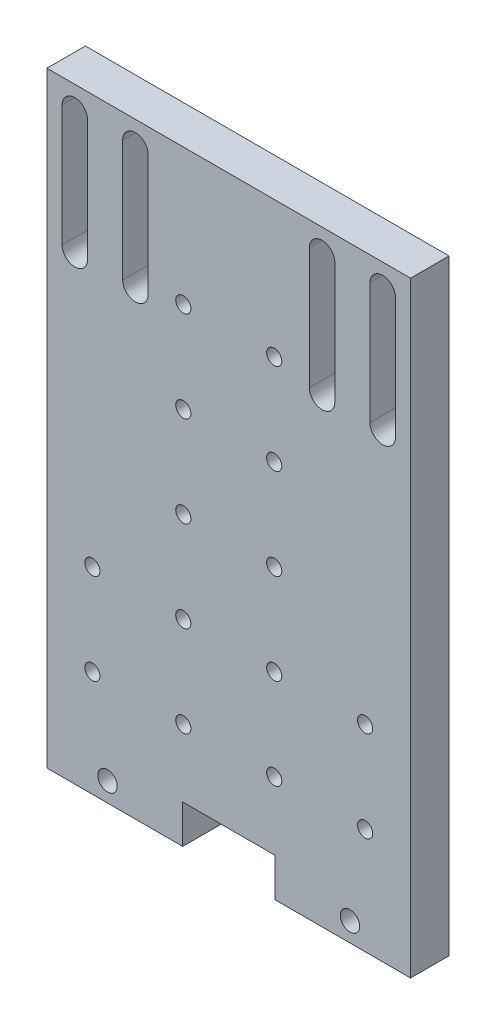
from build123d import *

# Parameters (mm, degrees)
BOSS_EXTRUDE1_DEPTH             = 6.35
F_2_5_2_5_DIAMETER_HOLE1_D      = 2.5
F_2_5_2_5_DIAMETER_HOLE1_DEPTH  = 6.35
F_3_2_3_2_DIAMETER_HOLE1_D      = 3.2
F_3_2_3_2_DIAMETER_HOLE1_DEPTH  = 6.35
F_2_5_2_5_DIAMETER_HOLE2_D      = 2.5
F_2_5_2_5_DIAMETER_HOLE2_DEPTH  = 6.35
F_2_5_2_5_DIAMETER_HOLE3_D      = 2.5
F_2_5_2_5_DIAMETER_HOLE3_DEPTH  = 6.35
F_2_5_2_5_DIAMETER_HOLE4_D      = 2.5
F_2_5_2_5_DIAMETER_HOLE4_DEPTH  = 6.35
F_2_5_2_5_DIAMETER_HOLE5_D      = 2.5
F_2_5_2_5_DIAMETER_HOLE5_DEPTH  = 6.35
F_2_5_2_5_DIAMETER_HOLE6_D      = 2.5
F_2_5_2_5_DIAMETER_HOLE6_DEPTH  = 6.35
F_2_5_2_5_DIAMETER_HOLE7_D      = 2.5
F_2_5_2_5_DIAMETER_HOLE7_DEPTH  = 6.35
F_2_5_2_5_DIAMETER_HOLE8_D      = 2.5
F_2_5_2_5_DIAMETER_HOLE8_DEPTH  = 6.35
F_2_5_2_5_DIAMETER_HOLE9_D      = 2.5
F_2_5_2_5_DIAMETER_HOLE9_DEPTH  = 6.35
F_2_5_2_5_DIAMETER_HOLE10_D     = 2.5
F_2_5_2_5_DIAMETER_HOLE10_DEPTH = 6.35
F_2_5_2_5_DIAMETER_HOLE11_D     = 2.5
F_2_5_2_5_DIAMETER_HOLE11_DEPTH = 6.35
F_2_5_2_5_DIAMETER_HOLE12_D     = 2.5
F_2_5_2_5_DIAMETER_HOLE12_DEPTH = 6.35
F_2_5_2_5_DIAMETER_HOLE13_D     = 2.5
F_2_5_2_5_DIAMETER_HOLE13_DEPTH = 6.35
F_2_5_2_5_DIAMETER_HOLE14_D     = 2.5
F_2_5_2_5_DIAMETER_HOLE14_DEPTH = 6.35
F_3_2_3_2_DIAMETER_HOLE2_D      = 3.2
F_3_2_3_2_DIAMETER_HOLE2_DEPTH  = 6.35
CUT_EXTRUDE1_DEPTH              = 7.35


with BuildPart() as part:
    # Sketch1 → Boss-Extrude1 (new body)
    with BuildSketch(Plane.XY.offset(118.288574318)):
        Polygon((19.634665341, 102.188959457), (19.634665341, 2.188959457), (42.034665341, 2.188959457), (42.034665341, 8.538959457), (57.234665341, 8.538959457), (57.234665341, 2.188959457), (79.634665341, 2.188959457), (79.634665341, 102.188959457), align=None)
    extrude(amount=-BOSS_EXTRUDE1_DEPTH)

    # Ø2.5 (2.5) Diameter Hole1
    with Locations(Plane(origin=(0, 0, 111.938574318), x_dir=(-1, 0, 0), z_dir=(0, 0, -1))):
        with Locations((-27.134665341, 19.688959457)):
            Hole(F_2_5_2_5_DIAMETER_HOLE1_D / 2, depth=F_2_5_2_5_DIAMETER_HOLE1_DEPTH)

    # Ø3.2 (3.2) Diameter Hole1
    with Locations(Plane.XY.offset(118.288574318)):
        with Locations((29.634665341, 5.363959457)):
            Hole(F_3_2_3_2_DIAMETER_HOLE1_D / 2, depth=F_3_2_3_2_DIAMETER_HOLE1_DEPTH)

    # Ø2.5 (2.5) Diameter Hole2
    with Locations(Plane(origin=(0, 0, 111.938574318), x_dir=(-1, 0, 0), z_dir=(0, 0, -1))):
        with Locations((-57.134665341, 19.688959457)):
            Hole(F_2_5_2_5_DIAMETER_HOLE2_D / 2, depth=F_2_5_2_5_DIAMETER_HOLE2_DEPTH)

    # Ø2.5 (2.5) Diameter Hole3
    with Locations(Plane(origin=(0, 0, 111.938574318), x_dir=(-1, 0, 0), z_dir=(0, 0, -1))):
        with Locations((-42.134665341, 34.688959457)):
            Hole(F_2_5_2_5_DIAMETER_HOLE3_D / 2, depth=F_2_5_2_5_DIAMETER_HOLE3_DEPTH)

    # Ø2.5 (2.5) Diameter Hole4
    with Locations(Plane(origin=(0, 0, 111.938574318), x_dir=(-1, 0, 0), z_dir=(0, 0, -1))):
        with Locations((-42.134665341, 64.688959457)):
            Hole(F_2_5_2_5_DIAMETER_HOLE4_D / 2, depth=F_2_5_2_5_DIAMETER_HOLE4_DEPTH)

    # Ø2.5 (2.5) Diameter Hole5
    with Locations(Plane(origin=(0, 0, 111.938574318), x_dir=(-1, 0, 0), z_dir=(0, 0, -1))):
        with Locations((-57.134665341, 64.688959457)):
            Hole(F_2_5_2_5_DIAMETER_HOLE5_D / 2, depth=F_2_5_2_5_DIAMETER_HOLE5_DEPTH)

    # Ø2.5 (2.5) Diameter Hole6
    with Locations(Plane(origin=(0, 0, 111.938574318), x_dir=(-1, 0, 0), z_dir=(0, 0, -1))):
        with Locations((-27.134665341, 34.688959457)):
            Hole(F_2_5_2_5_DIAMETER_HOLE6_D / 2, depth=F_2_5_2_5_DIAMETER_HOLE6_DEPTH)

    # Ø2.5 (2.5) Diameter Hole7
    with Locations(Plane(origin=(0, 0, 111.938574318), x_dir=(-1, 0, 0), z_dir=(0, 0, -1))):
        with Locations((-72.134665341, 19.688959457)):
            Hole(F_2_5_2_5_DIAMETER_HOLE7_D / 2, depth=F_2_5_2_5_DIAMETER_HOLE7_DEPTH)

    # Ø2.5 (2.5) Diameter Hole8
    with Locations(Plane(origin=(0, 0, 111.938574318), x_dir=(-1, 0, 0), z_dir=(0, 0, -1))):
        with Locations((-42.134665341, 19.688959457)):
            Hole(F_2_5_2_5_DIAMETER_HOLE8_D / 2, depth=F_2_5_2_5_DIAMETER_HOLE8_DEPTH)

    # Ø2.5 (2.5) Diameter Hole9
    with Locations(Plane(origin=(0, 0, 111.938574318), x_dir=(-1, 0, 0), z_dir=(0, 0, -1))):
        with Locations((-57.134665341, 34.688959457)):
            Hole(F_2_5_2_5_DIAMETER_HOLE9_D / 2, depth=F_2_5_2_5_DIAMETER_HOLE9_DEPTH)

    # Ø2.5 (2.5) Diameter Hole10
    with Locations(Plane(origin=(0, 0, 111.938574318), x_dir=(-1, 0, 0), z_dir=(0, 0, -1))):
        with Locations((-42.134665341, 49.688959457)):
            Hole(F_2_5_2_5_DIAMETER_HOLE10_D / 2, depth=F_2_5_2_5_DIAMETER_HOLE10_DEPTH)

    # Ø2.5 (2.5) Diameter Hole11
    with Locations(Plane(origin=(0, 0, 111.938574318), x_dir=(-1, 0, 0), z_dir=(0, 0, -1))):
        with Locations((-42.134665341, 79.688959457)):
            Hole(F_2_5_2_5_DIAMETER_HOLE11_D / 2, depth=F_2_5_2_5_DIAMETER_HOLE11_DEPTH)

    # Ø2.5 (2.5) Diameter Hole12
    with Locations(Plane(origin=(0, 0, 111.938574318), x_dir=(-1, 0, 0), z_dir=(0, 0, -1))):
        with Locations((-57.134665341, 79.688959457)):
            Hole(F_2_5_2_5_DIAMETER_HOLE12_D / 2, depth=F_2_5_2_5_DIAMETER_HOLE12_DEPTH)

    # Ø2.5 (2.5) Diameter Hole13
    with Locations(Plane(origin=(0, 0, 111.938574318), x_dir=(-1, 0, 0), z_dir=(0, 0, -1))):
        with Locations((-57.134665341, 49.688959457)):
            Hole(F_2_5_2_5_DIAMETER_HOLE13_D / 2, depth=F_2_5_2_5_DIAMETER_HOLE13_DEPTH)

    # Ø2.5 (2.5) Diameter Hole14
    with Locations(Plane(origin=(0, 0, 111.938574318), x_dir=(-1, 0, 0), z_dir=(0, 0, -1))):
        with Locations((-72.134665341, 34.688959457)):
            Hole(F_2_5_2_5_DIAMETER_HOLE14_D / 2, depth=F_2_5_2_5_DIAMETER_HOLE14_DEPTH)

    # Ø3.2 (3.2) Diameter Hole2
    with Locations(Plane.XY.offset(118.288574318)):
        with Locations((69.634665341, 5.363959457)):
            Hole(F_3_2_3_2_DIAMETER_HOLE2_D / 2, depth=F_3_2_3_2_DIAMETER_HOLE2_DEPTH)

    # Sketch38 → Cut-Extrude1 (cut, through all)
    with BuildSketch(Plane.XY.offset(118.288574318)):
        with BuildLine():
            Line((22.134665341, 98.188959457), (22.134665341, 78.188959457))
            ThreePointArc((22.134665341, 78.188959457), (24.234665341, 76.088959457), (26.334665341, 78.188959457))
            Line((26.334665341, 78.188959457), (26.334665341, 98.188959457))
            ThreePointArc((26.334665341, 98.188959457), (24.234665341, 100.288959457), (22.134665341, 98.188959457))
        make_face()
        with BuildLine():
            Line((32.134665341, 98.188959457), (32.134665341, 78.188959457))
            ThreePointArc((32.134665341, 78.188959457), (34.234665341, 76.088959457), (36.334665341, 78.188959457))
            Line((36.334665341, 78.188959457), (36.334665341, 98.188959457))
            ThreePointArc((36.334665341, 98.188959457), (34.234665341, 100.288959457), (32.134665341, 98.188959457))
        make_face()
        with BuildLine():
            Line((62.934665341, 98.188959457), (62.934665341, 78.188959457))
            ThreePointArc((62.934665341, 78.188959457), (65.034665341, 76.088959457), (67.134665341, 78.188959457))
            Line((67.134665341, 78.188959457), (67.134665341, 98.188959457))
            ThreePointArc((67.134665341, 98.188959457), (65.034665341, 100.288959457), (62.934665341, 98.188959457))
        make_face()
        with BuildLine():
            Line((72.934665341, 98.188959457), (72.934665341, 78.188959457))
            ThreePointArc((72.934665341, 78.188959457), (75.034665341, 76.088959457), (77.134665341, 78.188959457))
            Line((77.134665341, 78.188959457), (77.134665341, 98.188959457))
            ThreePointArc((77.134665341, 98.188959457), (75.034665341, 100.288959457), (72.934665341, 98.188959457))
        make_face()
    extrude(amount=-CUT_EXTRUDE1_DEPTH, mode=Mode.SUBTRACT)


solid = part.part
